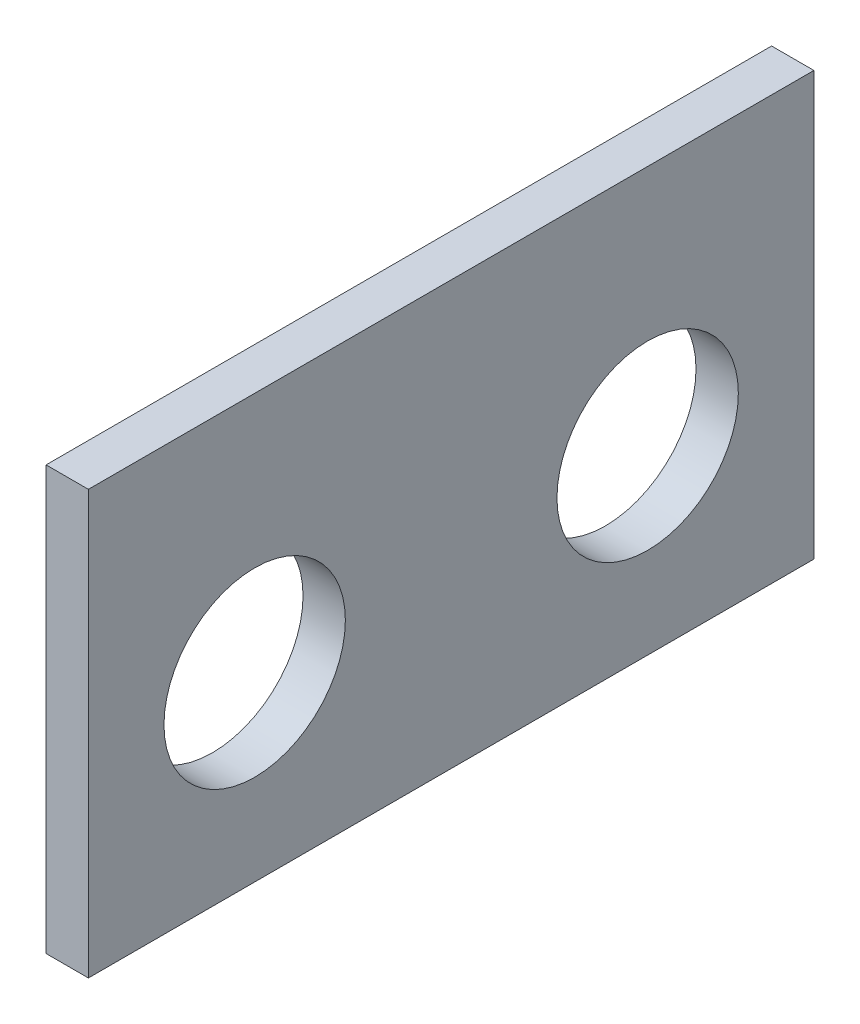
from build123d import *

# Parameters (mm, degrees)
SKETCH_1_W      = 12
SKETCH_1_H      = 7
SKETCH_1_R      = 1.5
EXTRUDE_1_DEPTH = 0.7


with BuildPart() as part:
    # 草图1 → 凸台-拉伸1 (new body)
    with BuildSketch(Plane(origin=(0, 0, 0), x_dir=(0, 0, -1), z_dir=(1, 0, 0))):
        with Locations((166.963773135, 64.074722086)):
            Rectangle(SKETCH_1_W, SKETCH_1_H)
        with Locations((170.213773135, 63.574722086)):
            Circle(SKETCH_1_R, mode=Mode.SUBTRACT)
        with Locations((163.713773135, 63.574722086)):
            Circle(SKETCH_1_R, mode=Mode.SUBTRACT)
    extrude(amount=EXTRUDE_1_DEPTH)


solid = part.part
